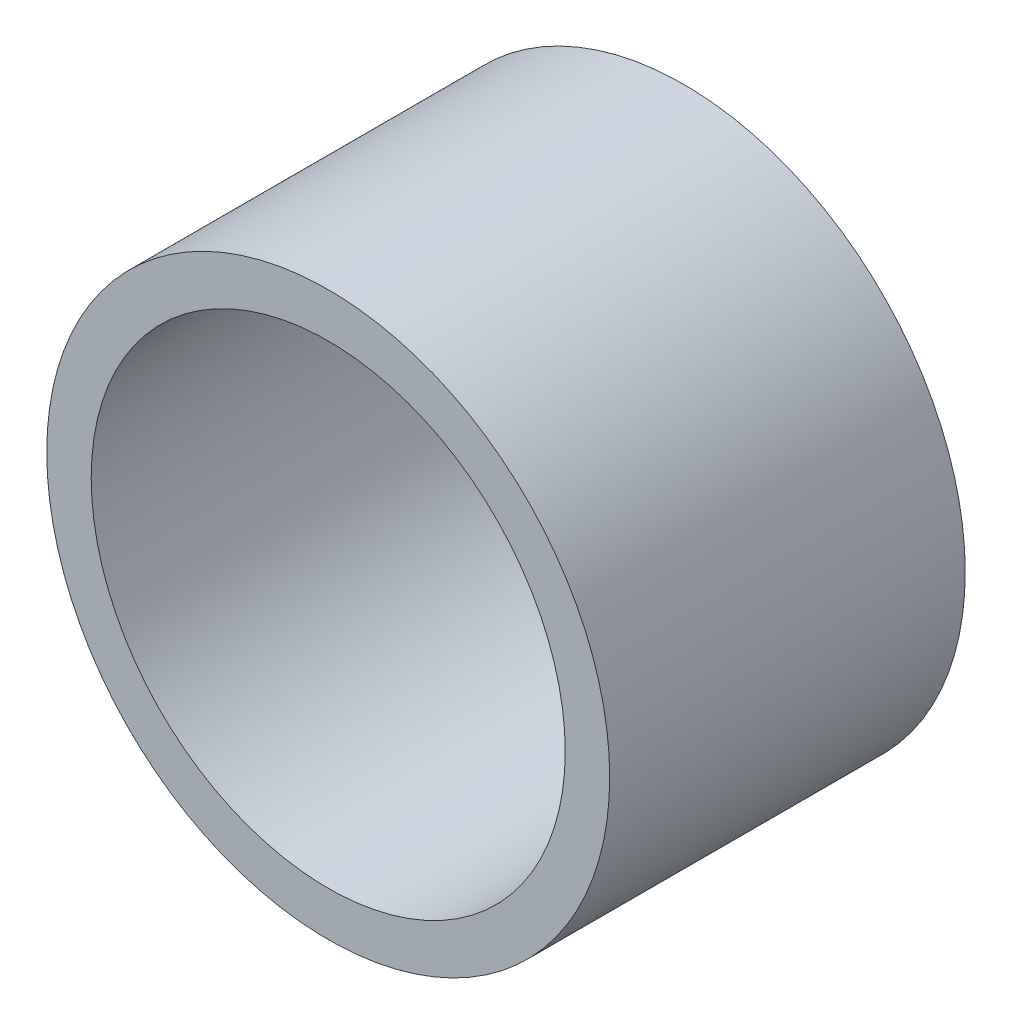
from build123d import *

# Parameters (mm, degrees)
SKETCH1_R           = 9.5
SKETCH1_R_2         = 8
BOSS_EXTRUDE1_DEPTH = 12


with BuildPart() as part:
    # Sketch1 → Boss-Extrude1 (new body)
    with BuildSketch(Plane.XY):
        Circle(SKETCH1_R)
        Circle(SKETCH1_R_2, mode=Mode.SUBTRACT)
    extrude(amount=BOSS_EXTRUDE1_DEPTH)


solid = part.part
